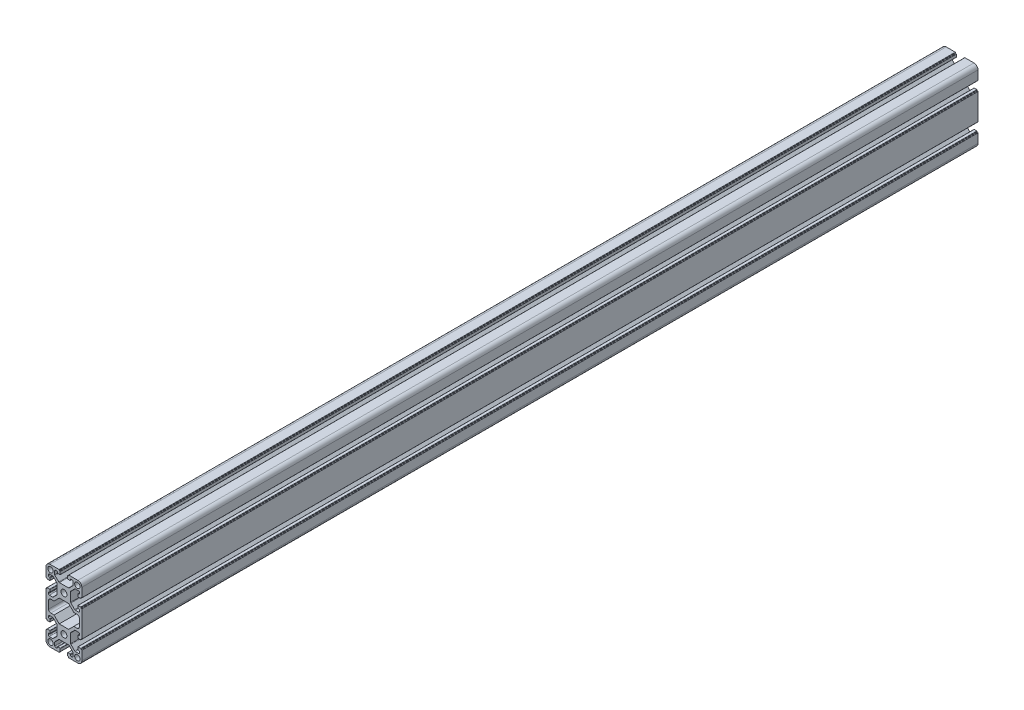
from build123d import *

# Parameters (mm, degrees)
SKETCH_1_R      = 3
SKETCH_1_R_2    = 3.35
EXTRUDE_1_DEPTH = 1000


with BuildPart() as part:
    # Эскиз1 → Бобышка-Вытянуть1 (new body)
    with BuildSketch(Plane.XY):
        with BuildLine():
            Line((-20, 15.5), (-20, 5.4))
            ThreePointArc((-20, 5.4), (-19.912132034, 5.187867966), (-19.7, 5.1))
            Line((-19.7, 5.1), (-19.3, 5.1))
            ThreePointArc((-19.3, 5.1), (-19.087867966, 5.012132034), (-19, 4.8))
            Line((-19, 4.8), (-19, 4.4))
            ThreePointArc((-19, 4.4), (-18.912132034, 4.187867966), (-18.7, 4.1))
            Line((-18.7, 4.1), (-15.8, 4.1))
            ThreePointArc((-15.8, 4.1), (-15.587867966, 4.187867966), (-15.5, 4.4))
            Line((-15.5, 4.4), (-15.5, 6.8))
            ThreePointArc((-15.5, 6.8), (-15.587867966, 7.012132034), (-15.8, 7.1))
            Line((-15.8, 7.1), (-16.3, 7.1))
            ThreePointArc((-16.3, 7.1), (-17.007106781, 7.392893219), (-17.3, 8.1))
            Line((-17.3, 8.1), (-17.3, 9.25))
            ThreePointArc((-17.3, 9.25), (-17.007106781, 9.957106781), (-16.3, 10.25))
            Line((-16.3, 10.25), (-12.664213562, 10.25))
            ThreePointArc((-12.664213562, 10.25), (-12.28153013, 10.173879533), (-11.957106781, 9.957106781))
            Line((-11.957106781, 9.957106781), (-7.792893219, 5.792893219))
            ThreePointArc((-7.792893219, 5.792893219), (-7.576120467, 5.46846987), (-7.5, 5.085786438))
            Line((-7.5, 5.085786438), (-7.5, -5.085786438))
            ThreePointArc((-7.5, -5.085786438), (-7.576120467, -5.46846987), (-7.792893219, -5.792893219))
            Line((-7.792893219, -5.792893219), (-11.957106781, -9.957106781))
            ThreePointArc((-11.957106781, -9.957106781), (-12.28153013, -10.173879533), (-12.664213562, -10.25))
            Line((-12.664213562, -10.25), (-16.3, -10.25))
            ThreePointArc((-16.3, -10.25), (-17.007106781, -9.957106781), (-17.3, -9.25))
            Line((-17.3, -9.25), (-17.3, -8.1))
            ThreePointArc((-17.3, -8.1), (-17.007106781, -7.392893219), (-16.3, -7.1))
            Line((-16.3, -7.1), (-15.8, -7.1))
            ThreePointArc((-15.8, -7.1), (-15.587867966, -7.012132034), (-15.5, -6.8))
            Line((-15.5, -6.8), (-15.5, -4.4))
            ThreePointArc((-15.5, -4.4), (-15.587867966, -4.187867966), (-15.8, -4.1))
            Line((-15.8, -4.1), (-18.7, -4.1))
            ThreePointArc((-18.7, -4.1), (-18.912132034, -4.187867966), (-19, -4.4))
            Line((-19, -4.4), (-19, -4.8))
            ThreePointArc((-19, -4.8), (-19.087867966, -5.012132034), (-19.3, -5.1))
            Line((-19.3, -5.1), (-19.7, -5.1))
            ThreePointArc((-19.7, -5.1), (-19.912132034, -5.187867966), (-20, -5.4))
            Line((-20, -5.4), (-20, -34.6))
            ThreePointArc((-20, -34.6), (-19.912132034, -34.812132034), (-19.7, -34.9))
            Line((-19.7, -34.9), (-19.3, -34.9))
            ThreePointArc((-19.3, -34.9), (-19.087867966, -34.987867966), (-19, -35.2))
            Line((-19, -35.2), (-19, -35.6))
            ThreePointArc((-19, -35.6), (-18.912132034, -35.812132034), (-18.7, -35.9))
            Line((-18.7, -35.9), (-15.8, -35.9))
            ThreePointArc((-15.8, -35.9), (-15.587867966, -35.812132034), (-15.5, -35.6))
            Line((-15.5, -35.6), (-15.5, -33.2))
            ThreePointArc((-15.5, -33.2), (-15.587867966, -32.987867966), (-15.8, -32.9))
            Line((-15.8, -32.9), (-16.3, -32.9))
            ThreePointArc((-16.3, -32.9), (-17.007106781, -32.607106781), (-17.3, -31.9))
            Line((-17.3, -31.9), (-17.3, -30.75))
            ThreePointArc((-17.3, -30.75), (-17.007106781, -30.042893219), (-16.3, -29.75))
            Line((-16.3, -29.75), (-12.664213562, -29.75))
            ThreePointArc((-12.664213562, -29.75), (-12.28153013, -29.826120467), (-11.957106781, -30.042893219))
            Line((-11.957106781, -30.042893219), (-7.792893219, -34.207106781))
            ThreePointArc((-7.792893219, -34.207106781), (-7.576120467, -34.53153013), (-7.5, -34.914213562))
            Line((-7.5, -34.914213562), (-7.5, -45.085786438))
            ThreePointArc((-7.5, -45.085786438), (-7.576120467, -45.46846987), (-7.792893219, -45.792893219))
            Line((-7.792893219, -45.792893219), (-11.957106781, -49.957106781))
            ThreePointArc((-11.957106781, -49.957106781), (-12.28153013, -50.173879533), (-12.664213562, -50.25))
            Line((-12.664213562, -50.25), (-16.3, -50.25))
            ThreePointArc((-16.3, -50.25), (-17.007106781, -49.957106781), (-17.3, -49.25))
            Line((-17.3, -49.25), (-17.3, -48.1))
            ThreePointArc((-17.3, -48.1), (-17.007106781, -47.392893219), (-16.3, -47.1))
            Line((-16.3, -47.1), (-15.8, -47.1))
            ThreePointArc((-15.8, -47.1), (-15.587867966, -47.012132034), (-15.5, -46.8))
            Line((-15.5, -46.8), (-15.5, -44.4))
            ThreePointArc((-15.5, -44.4), (-15.587867966, -44.187867966), (-15.8, -44.1))
            Line((-15.8, -44.1), (-18.7, -44.1))
            ThreePointArc((-18.7, -44.1), (-18.912132034, -44.187867966), (-19, -44.4))
            Line((-19, -44.4), (-19, -44.8))
            ThreePointArc((-19, -44.8), (-19.087867966, -45.012132034), (-19.3, -45.1))
            Line((-19.3, -45.1), (-19.7, -45.1))
            ThreePointArc((-19.7, -45.1), (-19.912132034, -45.187867966), (-20, -45.4))
            Line((-20, -45.4), (-20, -55.5))
            ThreePointArc((-20, -55.5), (-18.681980515, -58.681980515), (-15.5, -60))
            Line((-15.5, -60), (-5.4, -60))
            ThreePointArc((-5.4, -60), (-5.187867966, -59.912132034), (-5.1, -59.7))
            Line((-5.1, -59.7), (-5.1, -59.3))
            ThreePointArc((-5.1, -59.3), (-5.012132034, -59.087867966), (-4.8, -59))
            Line((-4.8, -59), (-4.4, -59))
            ThreePointArc((-4.4, -59), (-4.187867966, -58.912132034), (-4.1, -58.7))
            Line((-4.1, -58.7), (-4.1, -55.8))
            ThreePointArc((-4.1, -55.8), (-4.187867966, -55.587867966), (-4.4, -55.5))
            Line((-4.4, -55.5), (-6.8, -55.5))
            ThreePointArc((-6.8, -55.5), (-7.012132034, -55.587867966), (-7.1, -55.8))
            Line((-7.1, -55.8), (-7.1, -56.3))
            ThreePointArc((-7.1, -56.3), (-7.392893219, -57.007106781), (-8.1, -57.3))
            Line((-8.1, -57.3), (-9.25, -57.3))
            ThreePointArc((-9.25, -57.3), (-9.957106781, -57.007106781), (-10.25, -56.3))
            Line((-10.25, -56.3), (-10.25, -52.664213562))
            ThreePointArc((-10.25, -52.664213562), (-10.173879533, -52.28153013), (-9.957106781, -51.957106781))
            Line((-9.957106781, -51.957106781), (-5.792893219, -47.792893219))
            ThreePointArc((-5.792893219, -47.792893219), (-5.46846987, -47.576120467), (-5.085786438, -47.5))
            Line((-5.085786438, -47.5), (5.085786438, -47.5))
            ThreePointArc((5.085786438, -47.5), (5.46846987, -47.576120467), (5.792893219, -47.792893219))
            Line((5.792893219, -47.792893219), (9.957106781, -51.957106781))
            ThreePointArc((9.957106781, -51.957106781), (10.173879533, -52.28153013), (10.25, -52.664213562))
            Line((10.25, -52.664213562), (10.25, -56.3))
            ThreePointArc((10.25, -56.3), (9.957106781, -57.007106781), (9.25, -57.3))
            Line((9.25, -57.3), (8.1, -57.3))
            ThreePointArc((8.1, -57.3), (7.392893219, -57.007106781), (7.1, -56.3))
            Line((7.1, -56.3), (7.1, -55.8))
            ThreePointArc((7.1, -55.8), (7.012132034, -55.587867966), (6.8, -55.5))
            Line((6.8, -55.5), (4.4, -55.5))
            ThreePointArc((4.4, -55.5), (4.187867966, -55.587867966), (4.1, -55.8))
            Line((4.1, -55.8), (4.1, -58.7))
            ThreePointArc((4.1, -58.7), (4.187867966, -58.912132034), (4.4, -59))
            Line((4.4, -59), (4.8, -59))
            ThreePointArc((4.8, -59), (5.012132034, -59.087867966), (5.1, -59.3))
            Line((5.1, -59.3), (5.1, -59.7))
            ThreePointArc((5.1, -59.7), (5.187867966, -59.912132034), (5.4, -60))
            Line((5.4, -60), (15.5, -60))
            ThreePointArc((15.5, -60), (18.681980515, -58.681980515), (20, -55.5))
            Line((20, -55.5), (20, -45.4))
            ThreePointArc((20, -45.4), (19.912132034, -45.187867966), (19.7, -45.1))
            Line((19.7, -45.1), (19.3, -45.1))
            ThreePointArc((19.3, -45.1), (19.087867966, -45.012132034), (19, -44.8))
            Line((19, -44.8), (19, -44.4))
            ThreePointArc((19, -44.4), (18.912132034, -44.187867966), (18.7, -44.1))
            Line((18.7, -44.1), (15.8, -44.1))
            ThreePointArc((15.8, -44.1), (15.587867966, -44.187867966), (15.5, -44.4))
            Line((15.5, -44.4), (15.5, -46.8))
            ThreePointArc((15.5, -46.8), (15.587867966, -47.012132034), (15.8, -47.1))
            Line((15.8, -47.1), (16.3, -47.1))
            ThreePointArc((16.3, -47.1), (17.007106781, -47.392893219), (17.3, -48.1))
            Line((17.3, -48.1), (17.3, -49.25))
            ThreePointArc((17.3, -49.25), (17.007106781, -49.957106781), (16.3, -50.25))
            Line((16.3, -50.25), (12.664213562, -50.25))
            ThreePointArc((12.664213562, -50.25), (12.28153013, -50.173879533), (11.957106781, -49.957106781))
            Line((11.957106781, -49.957106781), (7.792893219, -45.792893219))
            ThreePointArc((7.792893219, -45.792893219), (7.576120467, -45.46846987), (7.5, -45.085786438))
            Line((7.5, -45.085786438), (7.5, -34.914213562))
            ThreePointArc((7.5, -34.914213562), (7.576120467, -34.53153013), (7.792893219, -34.207106781))
            Line((7.792893219, -34.207106781), (11.957106781, -30.042893219))
            ThreePointArc((11.957106781, -30.042893219), (12.28153013, -29.826120467), (12.664213562, -29.75))
            Line((12.664213562, -29.75), (16.3, -29.75))
            ThreePointArc((16.3, -29.75), (17.007106781, -30.042893219), (17.3, -30.75))
            Line((17.3, -30.75), (17.3, -31.9))
            ThreePointArc((17.3, -31.9), (17.007106781, -32.607106781), (16.3, -32.9))
            Line((16.3, -32.9), (15.8, -32.9))
            ThreePointArc((15.8, -32.9), (15.587867966, -32.987867966), (15.5, -33.2))
            Line((15.5, -33.2), (15.5, -35.6))
            ThreePointArc((15.5, -35.6), (15.587867966, -35.812132034), (15.8, -35.9))
            Line((15.8, -35.9), (18.7, -35.9))
            ThreePointArc((18.7, -35.9), (18.912132034, -35.812132034), (19, -35.6))
            Line((19, -35.6), (19, -35.2))
            ThreePointArc((19, -35.2), (19.087867966, -34.987867966), (19.3, -34.9))
            Line((19.3, -34.9), (19.7, -34.9))
            ThreePointArc((19.7, -34.9), (19.912132034, -34.812132034), (20, -34.6))
            Line((20, -34.6), (20, -5.4))
            ThreePointArc((20, -5.4), (19.912132034, -5.187867966), (19.7, -5.1))
            Line((19.7, -5.1), (19.3, -5.1))
            ThreePointArc((19.3, -5.1), (19.087867966, -5.012132034), (19, -4.8))
            Line((19, -4.8), (19, -4.4))
            ThreePointArc((19, -4.4), (18.912132034, -4.187867966), (18.7, -4.1))
            Line((18.7, -4.1), (15.8, -4.1))
            ThreePointArc((15.8, -4.1), (15.587867966, -4.187867966), (15.5, -4.4))
            Line((15.5, -4.4), (15.5, -6.8))
            ThreePointArc((15.5, -6.8), (15.587867966, -7.012132034), (15.8, -7.1))
            Line((15.8, -7.1), (16.3, -7.1))
            ThreePointArc((16.3, -7.1), (17.007106781, -7.392893219), (17.3, -8.1))
            Line((17.3, -8.1), (17.3, -9.25))
            ThreePointArc((17.3, -9.25), (17.007106781, -9.957106781), (16.3, -10.25))
            Line((16.3, -10.25), (12.664213562, -10.25))
            ThreePointArc((12.664213562, -10.25), (12.28153013, -10.173879533), (11.957106781, -9.957106781))
            Line((11.957106781, -9.957106781), (7.792893219, -5.792893219))
            ThreePointArc((7.792893219, -5.792893219), (7.576120467, -5.46846987), (7.5, -5.085786438))
            Line((7.5, -5.085786438), (7.5, 5.085786438))
            ThreePointArc((7.5, 5.085786438), (7.576120467, 5.46846987), (7.792893219, 5.792893219))
            Line((7.792893219, 5.792893219), (11.957106781, 9.957106781))
            ThreePointArc((11.957106781, 9.957106781), (12.28153013, 10.173879533), (12.664213562, 10.25))
            Line((12.664213562, 10.25), (16.3, 10.25))
            ThreePointArc((16.3, 10.25), (17.007106781, 9.957106781), (17.3, 9.25))
            Line((17.3, 9.25), (17.3, 8.1))
            ThreePointArc((17.3, 8.1), (17.007106781, 7.392893219), (16.3, 7.1))
            Line((16.3, 7.1), (15.8, 7.1))
            ThreePointArc((15.8, 7.1), (15.587867966, 7.012132034), (15.5, 6.8))
            Line((15.5, 6.8), (15.5, 4.4))
            ThreePointArc((15.5, 4.4), (15.587867966, 4.187867966), (15.8, 4.1))
            Line((15.8, 4.1), (18.7, 4.1))
            ThreePointArc((18.7, 4.1), (18.912132034, 4.187867966), (19, 4.4))
            Line((19, 4.4), (19, 4.8))
            ThreePointArc((19, 4.8), (19.087867966, 5.012132034), (19.3, 5.1))
            Line((19.3, 5.1), (19.7, 5.1))
            ThreePointArc((19.7, 5.1), (19.912132034, 5.187867966), (20, 5.4))
            Line((20, 5.4), (20, 15.5))
            ThreePointArc((20, 15.5), (18.681980515, 18.681980515), (15.5, 20))
            Line((15.5, 20), (5.4, 20))
            ThreePointArc((5.4, 20), (5.187867966, 19.912132034), (5.1, 19.7))
            Line((5.1, 19.7), (5.1, 19.3))
            ThreePointArc((5.1, 19.3), (5.012132034, 19.087867966), (4.8, 19))
            Line((4.8, 19), (4.4, 19))
            ThreePointArc((4.4, 19), (4.187867966, 18.912132034), (4.1, 18.7))
            Line((4.1, 18.7), (4.1, 15.8))
            ThreePointArc((4.1, 15.8), (4.187867966, 15.587867966), (4.4, 15.5))
            Line((4.4, 15.5), (6.8, 15.5))
            ThreePointArc((6.8, 15.5), (7.012132034, 15.587867966), (7.1, 15.8))
            Line((7.1, 15.8), (7.1, 16.3))
            ThreePointArc((7.1, 16.3), (7.392893219, 17.007106781), (8.1, 17.3))
            Line((8.1, 17.3), (9.25, 17.3))
            ThreePointArc((9.25, 17.3), (9.957106781, 17.007106781), (10.25, 16.3))
            Line((10.25, 16.3), (10.25, 12.664213562))
            ThreePointArc((10.25, 12.664213562), (10.173879533, 12.28153013), (9.957106781, 11.957106781))
            Line((9.957106781, 11.957106781), (5.792893219, 7.792893219))
            ThreePointArc((5.792893219, 7.792893219), (5.46846987, 7.576120467), (5.085786438, 7.5))
            Line((5.085786438, 7.5), (-5.085786438, 7.5))
            ThreePointArc((-5.085786438, 7.5), (-5.46846987, 7.576120467), (-5.792893219, 7.792893219))
            Line((-5.792893219, 7.792893219), (-9.957106781, 11.957106781))
            ThreePointArc((-9.957106781, 11.957106781), (-10.173879533, 12.28153013), (-10.25, 12.664213562))
            Line((-10.25, 12.664213562), (-10.25, 16.3))
            ThreePointArc((-10.25, 16.3), (-9.957106781, 17.007106781), (-9.25, 17.3))
            Line((-9.25, 17.3), (-8.1, 17.3))
            ThreePointArc((-8.1, 17.3), (-7.392893219, 17.007106781), (-7.1, 16.3))
            Line((-7.1, 16.3), (-7.1, 15.8))
            ThreePointArc((-7.1, 15.8), (-7.012132034, 15.587867966), (-6.8, 15.5))
            Line((-6.8, 15.5), (-4.4, 15.5))
            ThreePointArc((-4.4, 15.5), (-4.187867966, 15.587867966), (-4.1, 15.8))
            Line((-4.1, 15.8), (-4.1, 18.7))
            ThreePointArc((-4.1, 18.7), (-4.187867966, 18.912132034), (-4.4, 19))
            Line((-4.4, 19), (-4.8, 19))
            ThreePointArc((-4.8, 19), (-5.012132034, 19.087867966), (-5.1, 19.3))
            Line((-5.1, 19.3), (-5.1, 19.7))
            ThreePointArc((-5.1, 19.7), (-5.187867966, 19.912132034), (-5.4, 20))
            Line((-5.4, 20), (-15.5, 20))
            ThreePointArc((-15.5, 20), (-18.681980515, 18.681980515), (-20, 15.5))
        make_face()
        with BuildLine():
            ThreePointArc((17.2, -24.25), (16.467766953, -26.017766953), (14.7, -26.75))
            Line((14.7, -26.75), (11.007359313, -26.75))
            Line((11.007359313, -26.75), (5.257359313, -32.5))
            Line((5.257359313, -32.5), (-5.257359313, -32.5))
            Line((-5.257359313, -32.5), (-11.007359313, -26.75))
            Line((-11.007359313, -26.75), (-14.7, -26.75))
            ThreePointArc((-14.7, -26.75), (-16.467766953, -26.017766953), (-17.2, -24.25))
            Line((-17.2, -24.25), (-17.2, -15.75))
            ThreePointArc((-17.2, -15.75), (-16.467766953, -13.982233047), (-14.7, -13.25))
            Line((-14.7, -13.25), (-11.007359313, -13.25))
            Line((-11.007359313, -13.25), (-5.257359313, -7.5))
            Line((-5.257359313, -7.5), (5.257359313, -7.5))
            Line((5.257359313, -7.5), (11.007359313, -13.25))
            Line((11.007359313, -13.25), (14.7, -13.25))
            ThreePointArc((14.7, -13.25), (16.467766953, -13.982233047), (17.2, -15.75))
            Line((17.2, -15.75), (17.2, -24.25))
        make_face(mode=Mode.SUBTRACT)
        with Locations((-15, 15)):
            Circle(SKETCH_1_R, mode=Mode.SUBTRACT)
        Circle(SKETCH_1_R_2, mode=Mode.SUBTRACT)
        with Locations((15, 15)):
            Circle(SKETCH_1_R, mode=Mode.SUBTRACT)
        with Locations((15, -55)):
            Circle(SKETCH_1_R, mode=Mode.SUBTRACT)
        with Locations((0, -40)):
            Circle(SKETCH_1_R_2, mode=Mode.SUBTRACT)
        with Locations((-15, -55)):
            Circle(SKETCH_1_R, mode=Mode.SUBTRACT)
    extrude(amount=EXTRUDE_1_DEPTH)


solid = part.part
